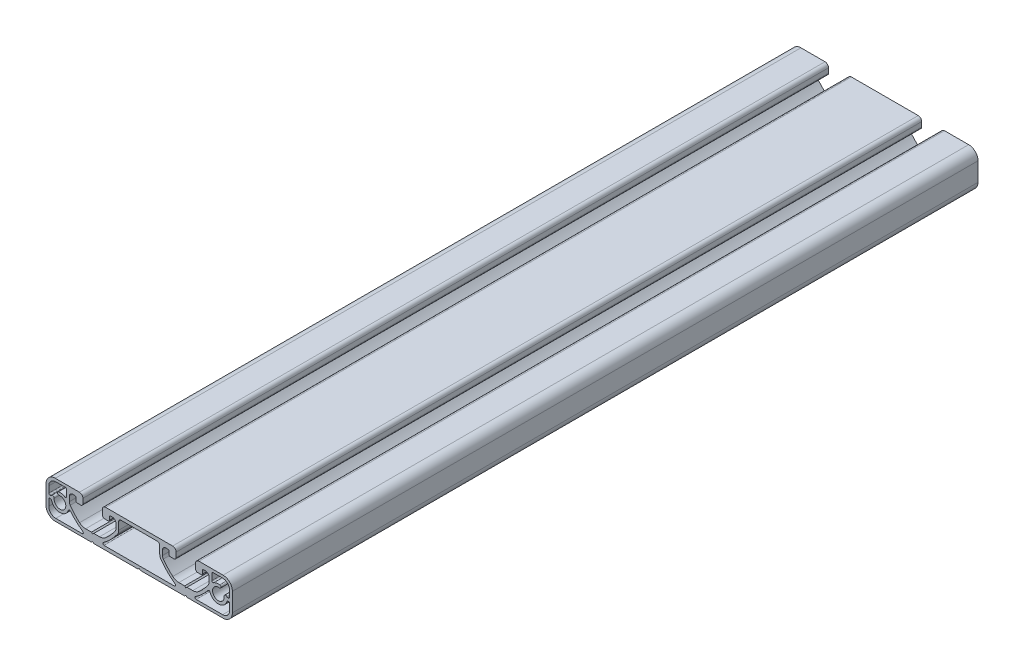
from build123d import *

# Parameters (mm, degrees)
BOSS_EXTRUDE2_DEPTH = 320


with BuildPart() as part:
    # Sketch → Boss-Extrude2 (new body)
    with BuildSketch(Plane.XY):
        with BuildLine():
            Line((24.150741464, 4.49971905), (24.150741464, 6.5))
            ThreePointArc((24.150741464, 6.5), (24.590081292, 7.560660172), (25.650741464, 8))
            Line((25.650741464, 8), (35.999999998, 8))
            ThreePointArc((35.999999998, 8), (38.828427123, 6.828427125), (39.999999998, 4))
            Line((39.999999998, 4), (39.999999998, -4))
            ThreePointArc((39.999999998, -4), (38.828427123, -6.828427125), (35.999999998, -8))
            Line((35.999999998, -8), (20.500741464, -8))
            Line((20.500741464, -8), (20.000741464, -7.5))
            Line((20.000741464, -7.5), (19.500741464, -8))
            Line((19.500741464, -8), (0.49851707, -8))
            Line((0.49851707, -8), (-0.00148293, -7.5))
            Line((-0.00148293, -7.5), (-0.50148293, -8))
            Line((-0.50148293, -8), (-19.500741464, -8))
            Line((-19.500741464, -8), (-20.000741464, -7.5))
            Line((-20.000741464, -7.5), (-20.500741464, -8))
            Line((-20.500741464, -8), (-35.999999998, -8))
            ThreePointArc((-35.999999998, -8), (-38.828427123, -6.828427125), (-39.999999998, -4))
            Line((-39.999999998, -4), (-39.999999998, 4))
            ThreePointArc((-39.999999998, 4), (-38.828427123, 6.828427125), (-35.999999998, 8))
            Line((-35.999999998, 8), (-25.650741464, 8))
            ThreePointArc((-25.650741464, 8), (-24.590081292, 7.560660172), (-24.150741464, 6.5))
            Line((-24.150741464, 6.5), (-24.150741464, 4.49971905))
            ThreePointArc((-24.150741464, 4.49971905), (-24.443634683, 3.792612269), (-25.150741464, 3.49971905))
            Line((-25.150741464, 3.49971905), (-26.649652497, 3.49971905))
            ThreePointArc((-26.649652497, 3.49971905), (-27.003205888, 3.646165659), (-27.149652497, 3.99971905))
            Line((-27.149652497, 3.99971905), (-27.149652497, 5.316640368))
            ThreePointArc((-27.149652497, 5.316640368), (-27.296099107, 5.670193759), (-27.649652497, 5.816640368))
            Line((-27.649652497, 5.816640368), (-28.499652497, 5.816640368))
            ThreePointArc((-28.499652497, 5.816640368), (-29.560312669, 5.37730054), (-29.999652497, 4.316640368))
            Line((-29.999652497, 4.316640368), (-29.999652497, 2.307424331))
            ThreePointArc((-29.999652497, 2.307424331), (-29.904475638, 1.697794278), (-29.628003696, 1.146186899))
            ThreePointArc((-29.628003696, 1.146186899), (-27.741523837, -1.188759737), (-25.588792104, -3.280775066))
            ThreePointArc((-25.588792104, -3.280775066), (-24.370633302, -3.999873347), (-22.978351052, -4.249999998))
            Line((-22.978351052, -4.249999998), (-20.5, -4.249999998))
            Line((-20.5, -4.249999998), (-20, -4.749999998))
            Line((-20, -4.749999998), (-19.5, -4.249999998))
            Line((-19.5, -4.249999998), (-17.021648948, -4.249999998))
            ThreePointArc((-17.021648948, -4.249999998), (-15.629416857, -3.999891971), (-14.411288978, -3.280844901))
            ThreePointArc((-14.411288978, -3.280844901), (-12.258317545, -1.188680624), (-10.371648801, 1.146467852))
            ThreePointArc((-10.371648801, 1.146467852), (-10.095176859, 1.698075231), (-10, 2.307705283))
            Line((-10, 2.307705283), (-10, 4.316921318))
            ThreePointArc((-10, 4.316921318), (-10.439339828, 5.37758149), (-11.5, 5.816921318))
            Line((-11.5, 5.816921318), (-12.350000001, 5.816921318))
            ThreePointArc((-12.350000001, 5.816921318), (-12.703553392, 5.670474709), (-12.850000001, 5.316921318))
            Line((-12.850000001, 5.316921318), (-12.850000001, 4))
            ThreePointArc((-12.850000001, 4), (-12.996446611, 3.646446609), (-13.350000001, 3.5))
            Line((-13.350000001, 3.5), (-14.849258536, 3.5))
            ThreePointArc((-14.849258536, 3.5), (-15.556365317, 3.792893219), (-15.849258536, 4.5))
            Line((-15.849258536, 4.5), (-15.849258536, 6.5))
            ThreePointArc((-15.849258536, 6.5), (-15.409918708, 7.560660172), (-14.349258536, 8))
            Line((-14.349258536, 8), (14.349258536, 8))
            ThreePointArc((14.349258536, 8), (15.409918708, 7.560660172), (15.849258536, 6.5))
            Line((15.849258536, 6.5), (15.849258536, 4.5))
            ThreePointArc((15.849258536, 4.5), (15.556365317, 3.792893219), (14.849258536, 3.5))
            Line((14.849258536, 3.5), (13.350000001, 3.5))
            ThreePointArc((13.350000001, 3.5), (12.996446611, 3.646446609), (12.850000001, 4))
            Line((12.850000001, 4), (12.850000001, 5.316921318))
            ThreePointArc((12.850000001, 5.316921318), (12.703553392, 5.670474709), (12.350000001, 5.816921318))
            Line((12.350000001, 5.816921318), (11.5, 5.816921318))
            ThreePointArc((11.5, 5.816921318), (10.439339828, 5.37758149), (10, 4.316921318))
            Line((10, 4.316921318), (10, 2.307705283))
            ThreePointArc((10, 2.307705283), (10.095176859, 1.698075231), (10.371648801, 1.146467852))
            ThreePointArc((10.371648801, 1.146467852), (12.258317545, -1.188680624), (14.411288978, -3.280844901))
            ThreePointArc((14.411288978, -3.280844901), (15.629416857, -3.999891971), (17.021648948, -4.249999998))
            Line((17.021648948, -4.249999998), (19.5, -4.249999998))
            Line((19.5, -4.249999998), (20, -4.749999998))
            Line((20, -4.749999998), (20.5, -4.249999998))
            Line((20.5, -4.249999998), (22.978351052, -4.249999998))
            ThreePointArc((22.978351052, -4.249999998), (24.370633302, -3.999873347), (25.588792104, -3.280775066))
            ThreePointArc((25.588792104, -3.280775066), (27.741523837, -1.188759737), (29.628003696, 1.146186899))
            ThreePointArc((29.628003696, 1.146186899), (29.904475638, 1.697794278), (29.999652497, 2.307424331))
            Line((29.999652497, 2.307424331), (29.999652497, 4.316640368))
            ThreePointArc((29.999652497, 4.316640368), (29.560312669, 5.37730054), (28.499652497, 5.816640368))
            Line((28.499652497, 5.816640368), (27.649652497, 5.816640368))
            ThreePointArc((27.649652497, 5.816640368), (27.296099107, 5.670193759), (27.149652497, 5.316640368))
            Line((27.149652497, 5.316640368), (27.149652497, 3.99971905))
            ThreePointArc((27.149652497, 3.99971905), (27.003205888, 3.646165659), (26.649652497, 3.49971905))
            Line((26.649652497, 3.49971905), (25.150741464, 3.49971905))
            ThreePointArc((25.150741464, 3.49971905), (24.443634683, 3.792612269), (24.150741464, 4.49971905))
        make_face()
        with BuildLine():
            Line((15.116729392, -6.499999998), (-15.116729392, -6.499999998))
            ThreePointArc((-15.116729392, -6.499999998), (-15.592558727, -6.153578783), (-15.409038556, -5.594345771))
            ThreePointArc((-15.409038556, -5.594345771), (-12.154825411, -2.819136563), (-9.395482708, 0.44854108))
            ThreePointArc((-9.395482708, 0.44854108), (-8.953051519, 1.33117293), (-8.800741466, 2.306665619))
            Line((-8.800741466, 2.306665619), (-8.800741466, 5.500000002))
            ThreePointArc((-8.800741466, 5.500000002), (-8.507848247, 6.207106783), (-7.800741466, 6.500000002))
            Line((-7.800741466, 6.500000002), (7.800741466, 6.500000002))
            ThreePointArc((7.800741466, 6.500000002), (8.507848247, 6.207106783), (8.800741466, 5.500000002))
            Line((8.800741466, 5.500000002), (8.800741466, 2.306665619))
            ThreePointArc((8.800741466, 2.306665619), (8.953051519, 1.33117293), (9.395482708, 0.44854108))
            ThreePointArc((9.395482708, 0.44854108), (12.154825411, -2.819136563), (15.409038556, -5.594345771))
            ThreePointArc((15.409038556, -5.594345771), (15.592558727, -6.153578783), (15.116729392, -6.499999998))
        make_face(mode=Mode.SUBTRACT)
        with BuildLine():
            Line((-38.298517067, -0.6), (-38.103696722, -0.6))
            ThreePointArc((-38.103696722, -0.6), (-37.799316928, -0.703322624), (-37.62073441, -0.970588236))
            ThreePointArc((-37.62073441, -0.970588236), (-34.066439906, -3.749384815), (-30.41383071, -1.101146548))
            ThreePointArc((-30.41383071, -1.101146548), (-30.032220256, -0.757336782), (-29.548931466, -0.931301259))
            ThreePointArc((-29.548931466, -0.931301259), (-27.03486507, -3.598488846), (-24.173182868, -5.888727795))
            ThreePointArc((-24.173182868, -5.888727795), (-23.980230417, -6.448936056), (-24.457533309, -6.8))
            Line((-24.457533309, -6.8), (-35.798517067, -6.8))
            ThreePointArc((-35.798517067, -6.8), (-37.919837411, -5.921320344), (-38.798517067, -3.8))
            Line((-38.798517067, -3.8), (-38.798517067, -1.1))
            ThreePointArc((-38.798517067, -1.1), (-38.652070458, -0.74644661), (-38.298517067, -0.6))
        make_face(mode=Mode.SUBTRACT)
        with BuildLine():
            Line((-38.014643332, 0.6), (-38.298517067, 0.6))
            ThreePointArc((-38.298517067, 0.6), (-38.652070458, 0.74644661), (-38.798517067, 1.1))
            Line((-38.798517067, 1.1), (-38.798517067, 3.8))
            ThreePointArc((-38.798517067, 3.8), (-37.919837411, 5.921320343), (-35.798517067, 6.8))
            Line((-35.798517067, 6.8), (-31.698517068, 6.8))
            ThreePointArc((-31.698517068, 6.8), (-31.344963677, 6.65355339), (-31.198517068, 6.3))
            Line((-31.198517068, 6.3), (-31.198517068, 3.573863455))
            ThreePointArc((-31.198517068, 3.573863455), (-31.459032327, 3.134947679), (-31.969105303, 3.153408931))
            ThreePointArc((-31.969105303, 3.153408931), (-33.209224893, 3.665994798), (-34.550409851, 3.709166261))
            ThreePointArc((-34.550409851, 3.709166261), (-35.076622097, 2.998989753), (-34.36644559, 2.472777507))
            ThreePointArc((-34.36644559, 2.472777507), (-32.230750115, -1.767766953), (-36.471294575, 0.367928522))
            ThreePointArc((-36.471294575, 0.367928522), (-36.859708534, 1.041138628), (-37.603463608, 0.815515846))
            ThreePointArc((-37.603463608, 0.815515846), (-37.782524911, 0.65714445), (-38.014643332, 0.6))
        make_face(mode=Mode.SUBTRACT)
        with BuildLine():
            Line((31.198517068, 6.3), (31.198517068, 3.573863455))
            ThreePointArc((31.198517068, 3.573863455), (31.459032327, 3.134947679), (31.969105303, 3.153408931))
            ThreePointArc((31.969105303, 3.153408931), (33.209224893, 3.665994798), (34.550409851, 3.709166261))
            ThreePointArc((34.550409851, 3.709166261), (35.076622097, 2.998989753), (34.36644559, 2.472777507))
            ThreePointArc((34.36644559, 2.472777507), (32.230750115, -1.767766953), (36.471294575, 0.367928522))
            ThreePointArc((36.471294575, 0.367928522), (36.859708534, 1.041138628), (37.603463608, 0.815515846))
            ThreePointArc((37.603463608, 0.815515846), (37.782524911, 0.65714445), (38.014643332, 0.6))
            Line((38.014643332, 0.6), (38.298517067, 0.6))
            ThreePointArc((38.298517067, 0.6), (38.652070458, 0.74644661), (38.798517067, 1.1))
            Line((38.798517067, 1.1), (38.798517067, 3.8))
            ThreePointArc((38.798517067, 3.8), (37.919837411, 5.921320343), (35.798517067, 6.8))
            Line((35.798517067, 6.8), (31.698517068, 6.8))
            ThreePointArc((31.698517068, 6.8), (31.344963677, 6.65355339), (31.198517068, 6.3))
        make_face(mode=Mode.SUBTRACT)
        with BuildLine():
            Line((38.798517067, -3.8), (38.798517067, -1.1))
            ThreePointArc((38.798517067, -1.1), (38.652070458, -0.74644661), (38.298517067, -0.6))
            Line((38.298517067, -0.6), (38.103696722, -0.6))
            ThreePointArc((38.103696722, -0.6), (37.799316928, -0.703322624), (37.62073441, -0.970588236))
            ThreePointArc((37.62073441, -0.970588236), (34.066439906, -3.749384815), (30.41383071, -1.101146548))
            ThreePointArc((30.41383071, -1.101146548), (30.032220256, -0.757336782), (29.548931466, -0.931301259))
            ThreePointArc((29.548931466, -0.931301259), (27.03486507, -3.598488846), (24.173182868, -5.888727795))
            ThreePointArc((24.173182868, -5.888727795), (23.980230417, -6.448936056), (24.457533309, -6.8))
            Line((24.457533309, -6.8), (35.798517067, -6.8))
            ThreePointArc((35.798517067, -6.8), (37.919837411, -5.921320344), (38.798517067, -3.8))
        make_face(mode=Mode.SUBTRACT)
    extrude(amount=BOSS_EXTRUDE2_DEPTH)


solid = part.part
